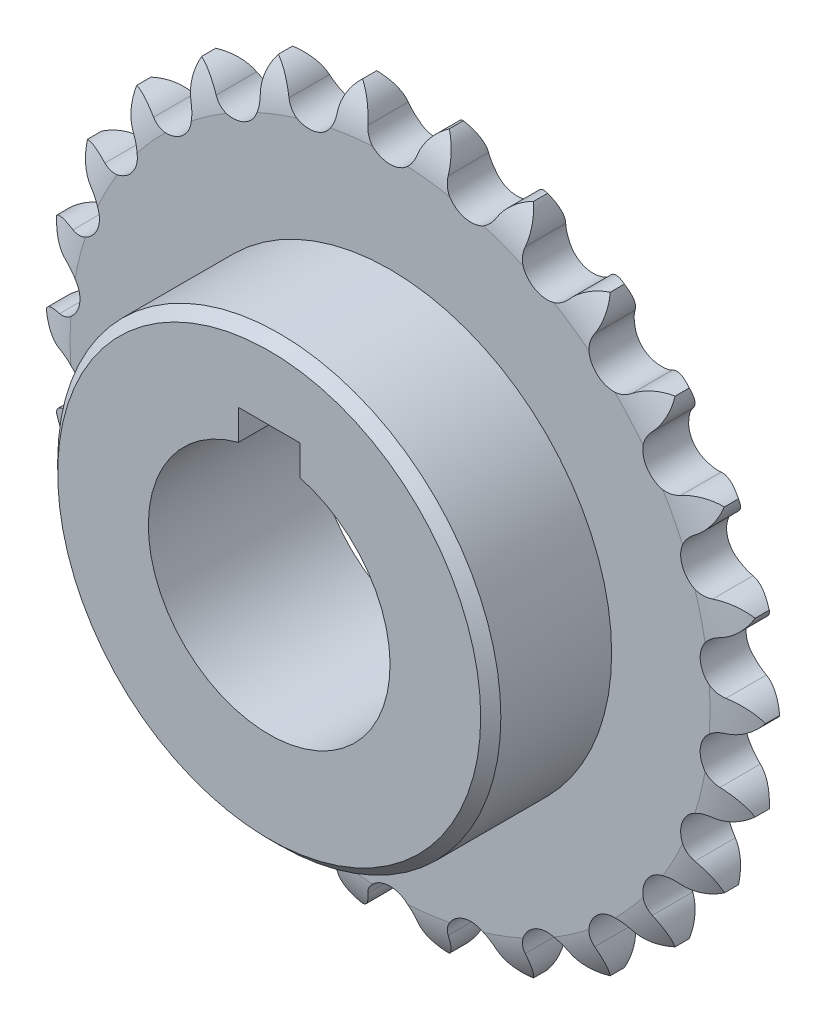
from build123d import *

# Parameters (mm, degrees)
SKETCH1_R           = 19.05
BOSS_EXTRUDE1_DEPTH = 3.6155
SKETCH2_W           = 19.05
SKETCH2_H           = 15.875
SKETCH3_W           = 9.65
SKETCH3_H           = 4.76
CUT_EXTRUDE1_DEPTH  = 27.281
CHAMFER2_SIZE       = 1.5875
SCALE_1_SCALE       = 0.111111111


with BuildPart() as part:
    # Sketch1 → Boss-Extrude1 (new body, symmetric)
    with BuildSketch(Plane.XY):
        with BuildLine():
            ThreePointArc((6.832203091, 56.268254805), (4.963717297, 54.655608899), (3.929721647, 52.414466562))
            ThreePointArc((3.929721647, 52.414466562), (0, 49.2633), (-3.929721647, 52.414466562))
            ThreePointArc((-3.929721647, 52.414466562), (-4.963717297, 54.655608899), (-6.832203091, 56.268254805))
            ThreePointArc((-6.832203091, 56.268254805), (-8.260462658, 54.25531154), (-8.728071806, 51.831841369))
            ThreePointArc((-8.728071806, 51.831841369), (-11.789479364, 47.831798034), (-16.359133961, 49.950953477))
            ThreePointArc((-16.359133961, 49.950953477), (-17.899424044, 51.879520935), (-20.099546463, 52.998148363))
            ThreePointArc((-20.099546463, 52.998148363), (-21.004574548, 50.701892683), (-20.87862145, 48.236937958))
            ThreePointArc((-20.87862145, 48.236937958), (-22.893797041, 43.620485829), (-27.837812873, 44.58447254))
            ThreePointArc((-27.837812873, 44.58447254), (-29.794881328, 46.088383789), (-32.198777254, 46.647982178))
            ThreePointArc((-32.198777254, 46.647982178), (-32.527976914, 44.201864118), (-31.815781507, 41.838679046))
            ThreePointArc((-31.815781507, 41.838679046), (-32.66761045, 36.87410954), (-37.698659287, 36.626904117))
            ThreePointArc((-37.698659287, 36.626904117), (-39.958768409, 37.618757301), (-42.426732148, 37.586804827))
            ThreePointArc((-42.426732148, 37.586804827), (-42.160971496, 35.132983877), (-40.903923988, 33.008908185))
            ThreePointArc((-40.903923988, 33.008908185), (-40.542901081, 27.984744038), (-45.368596652, 26.54071316))
            ThreePointArc((-45.368596652, 26.54071316), (-47.800397114, 26.962865377), (-50.188999585, 26.341219003))
            ThreePointArc((-50.188999585, 26.341219003), (-49.343723664, 24.022302317), (-47.614879086, 22.260779564))
            ThreePointArc((-47.614879086, 22.260779564), (-46.061985668, 17.469006932), (-50.401876088, 14.912072425))
            ThreePointArc((-50.401876088, 14.912072425), (-52.864040486, 14.739989724), (-55.034464796, 13.564777276))
            ThreePointArc((-55.034464796, 13.564777276), (-53.658797969, 11.515531863), (-51.558630485, 10.218935348))
            ThreePointArc((-51.558630485, 10.218935348), (-48.904115077, 5.93803464), (-52.505981689, 2.416796245))
            ThreePointArc((-52.505981689, 2.416796245), (-54.855417978, 1.660479445), (-56.681526955, 0))
            ThreePointArc((-56.681526955, 0), (-54.855417978, -1.660479445), (-52.505981689, -2.416796245))
            ThreePointArc((-52.505981689, -2.416796245), (-48.904115077, -5.93803464), (-51.558630485, -10.218935348))
            ThreePointArc((-51.558630485, -10.218935348), (-53.658797969, -11.515531863), (-55.034464796, -13.564777276))
            ThreePointArc((-55.034464796, -13.564777276), (-52.864040486, -14.739989724), (-50.401876088, -14.912072425))
            ThreePointArc((-50.401876088, -14.912072425), (-46.061985668, -17.469006932), (-47.614879086, -22.260779564))
            ThreePointArc((-47.614879086, -22.260779564), (-49.343723664, -24.022302317), (-50.188999585, -26.341219003))
            ThreePointArc((-50.188999585, -26.341219003), (-47.800397114, -26.962865377), (-45.368596652, -26.54071316))
            ThreePointArc((-45.368596652, -26.54071316), (-40.542901081, -27.984744038), (-40.903923988, -33.008908185))
            ThreePointArc((-40.903923988, -33.008908185), (-42.160971496, -35.132983877), (-42.426732148, -37.586804827))
            ThreePointArc((-42.426732148, -37.586804827), (-39.958768409, -37.618757301), (-37.698659287, -36.626904117))
            ThreePointArc((-37.698659287, -36.626904117), (-32.66761045, -36.87410954), (-31.815781507, -41.838679046))
            ThreePointArc((-31.815781507, -41.838679046), (-32.527976914, -44.201864118), (-32.198777254, -46.647982178))
            ThreePointArc((-32.198777254, -46.647982178), (-29.794881328, -46.088383789), (-27.837812873, -44.58447254))
            ThreePointArc((-27.837812873, -44.58447254), (-22.893797041, -43.620485829), (-20.87862145, -48.236937958))
            ThreePointArc((-20.87862145, -48.236937958), (-21.004574548, -50.701892683), (-20.099546463, -52.998148363))
            ThreePointArc((-20.099546463, -52.998148363), (-17.899424044, -51.879520935), (-16.359133961, -49.950953477))
            ThreePointArc((-16.359133961, -49.950953477), (-11.789479364, -47.831798034), (-8.728071806, -51.831841369))
            ThreePointArc((-8.728071806, -51.831841369), (-8.260462658, -54.25531154), (-6.832203091, -56.268254805))
            ThreePointArc((-6.832203091, -56.268254805), (-4.963717297, -54.655608899), (-3.929721647, -52.414466562))
            ThreePointArc((-3.929721647, -52.414466562), (0, -49.2633), (3.929721647, -52.414466562))
            ThreePointArc((3.929721647, -52.414466562), (4.963717297, -54.655608899), (6.832203091, -56.268254805))
            ThreePointArc((6.832203091, -56.268254805), (8.260462658, -54.25531154), (8.728071806, -51.831841369))
            ThreePointArc((8.728071806, -51.831841369), (11.789479365, -47.831798034), (16.359133961, -49.950953477))
            ThreePointArc((16.359133961, -49.950953477), (17.899424044, -51.879520935), (20.099546463, -52.998148363))
            ThreePointArc((20.099546463, -52.998148363), (21.004574548, -50.701892683), (20.87862145, -48.236937958))
            ThreePointArc((20.87862145, -48.236937958), (22.893797041, -43.620485829), (27.837812873, -44.58447254))
            ThreePointArc((27.837812873, -44.58447254), (29.794881328, -46.088383789), (32.198777254, -46.647982178))
            ThreePointArc((32.198777254, -46.647982178), (32.527976914, -44.201864118), (31.815781507, -41.838679046))
            ThreePointArc((31.815781507, -41.838679046), (32.66761045, -36.87410954), (37.698659287, -36.626904117))
            ThreePointArc((37.698659287, -36.626904117), (39.958768409, -37.618757301), (42.426732148, -37.586804827))
            ThreePointArc((42.426732148, -37.586804827), (42.160971496, -35.132983877), (40.903923988, -33.008908185))
            ThreePointArc((40.903923988, -33.008908185), (40.542901081, -27.984744038), (45.368596652, -26.54071316))
            ThreePointArc((45.368596652, -26.54071316), (47.800397114, -26.962865377), (50.188999585, -26.341219003))
            ThreePointArc((50.188999585, -26.341219003), (49.343723664, -24.022302317), (47.614879086, -22.260779564))
            ThreePointArc((47.614879086, -22.260779564), (46.061985668, -17.469006932), (50.401876088, -14.912072425))
            ThreePointArc((50.401876088, -14.912072425), (52.864040486, -14.739989724), (55.034464796, -13.564777276))
            ThreePointArc((55.034464796, -13.564777276), (53.658797969, -11.515531863), (51.558630485, -10.218935348))
            ThreePointArc((51.558630485, -10.218935348), (48.904115077, -5.93803464), (52.505981689, -2.416796245))
            ThreePointArc((52.505981689, -2.416796245), (54.855417978, -1.660479445), (56.681526955, 0))
            ThreePointArc((56.681526955, 0), (54.855417978, 1.660479445), (52.505981689, 2.416796245))
            ThreePointArc((52.505981689, 2.416796245), (48.904115077, 5.93803464), (51.558630485, 10.218935348))
            ThreePointArc((51.558630485, 10.218935348), (53.658797969, 11.515531863), (55.034464796, 13.564777276))
            ThreePointArc((55.034464796, 13.564777276), (52.864040486, 14.739989724), (50.401876088, 14.912072425))
            ThreePointArc((50.401876088, 14.912072425), (46.061985668, 17.469006932), (47.614879086, 22.260779564))
            ThreePointArc((47.614879086, 22.260779564), (49.343723664, 24.022302317), (50.188999585, 26.341219003))
            ThreePointArc((50.188999585, 26.341219003), (47.800397114, 26.962865377), (45.368596652, 26.54071316))
            ThreePointArc((45.368596652, 26.54071316), (40.542901081, 27.984744038), (40.903923988, 33.008908185))
            ThreePointArc((40.903923988, 33.008908185), (42.160971496, 35.132983877), (42.426732148, 37.586804827))
            ThreePointArc((42.426732148, 37.586804827), (39.958768409, 37.618757301), (37.698659287, 36.626904117))
            ThreePointArc((37.698659287, 36.626904117), (32.66761045, 36.87410954), (31.815781507, 41.838679046))
            ThreePointArc((31.815781507, 41.838679046), (32.527976914, 44.201864118), (32.198777254, 46.647982178))
            ThreePointArc((32.198777254, 46.647982178), (29.794881328, 46.088383789), (27.837812873, 44.58447254))
            ThreePointArc((27.837812873, 44.58447254), (22.893797041, 43.620485829), (20.87862145, 48.236937958))
            ThreePointArc((20.87862145, 48.236937958), (21.004574548, 50.701892683), (20.099546463, 52.998148363))
            ThreePointArc((20.099546463, 52.998148363), (17.899424044, 51.879520935), (16.359133961, 49.950953477))
            ThreePointArc((16.359133961, 49.950953477), (11.789479364, 47.831798034), (8.728071806, 51.831841369))
            ThreePointArc((8.728071806, 51.831841369), (8.260462658, 54.25531154), (6.832203091, 56.268254805))
        make_face()
        Circle(SKETCH1_R, mode=Mode.SUBTRACT)
    extrude(amount=BOSS_EXTRUDE1_DEPTH, both=True)

    # Sketch2 → Revolve1 (revolve)
    with BuildSketch(Plane(origin=(0, 0, 0), x_dir=(0, 0, -1), z_dir=(1, 0, 0))):
        with Locations((-13.1405, 26.9875)):
            Rectangle(SKETCH2_W, SKETCH2_H)
    revolve(axis=Axis((0, 0, 0), (0, 0, 1)))

    # Sketch3 → Cut-Extrude1 (cut, through all)
    with BuildSketch(Plane.XY.offset(22.6655)):
        with Locations((0, 20.808832709)):
            Rectangle(SKETCH3_W, SKETCH3_H)
    extrude(amount=-CUT_EXTRUDE1_DEPTH, mode=Mode.SUBTRACT)

    # Sketch4 → Cut-Revolve1 (revolve, cut)
    with BuildSketch(Plane(origin=(0, 0, 0), x_dir=(0, 0, -1), z_dir=(1, 0, 0))):
        with BuildLine():
            Line((-3.6155, 50.42), (-12.330867659, 50.42))
            Line((-12.330867659, 50.42), (-12.330867659, 56.89))
            Line((-12.330867659, 56.89), (-0.954045736, 56.89))
            ThreePointArc((-0.954045736, 56.89), (-2.739073023, 53.841877757), (-3.6155, 50.42))
        make_face()
    cut_revolve1 = revolve(axis=Axis((0, 0, 0), (0, 0, 1)), mode=Mode.SUBTRACT)

    # Mirror1: Cut-Revolve1 across plane
    add(cut_revolve1.mirror(Plane.XY), mode=Mode.SUBTRACT)

    # Chamfer2
    chamfer2_edges = [part.edges().sort_by_distance(p)[0] for p in [
        (0, -34.925, 22.6655),
    ]]
    chamfer(chamfer2_edges, length=CHAMFER2_SIZE)


with BuildPart() as part_1:
    # Scale 1: scaled about (-9e-09, -0.225936899, 6.41471309)
    add(part.part.scale(SCALE_1_SCALE).moved(Location((-8e-09, -0.200832799, 5.701967191))))


solid = part_1.part
